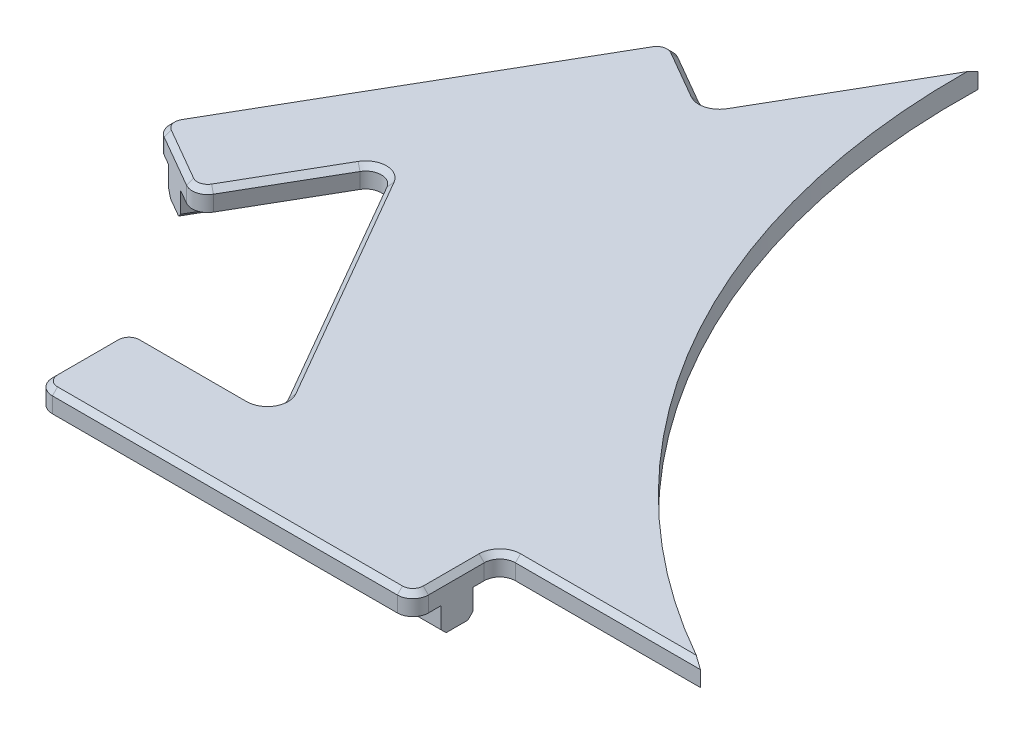
from build123d import *

# Parameters (mm, degrees)
BOSS_EXTRUDE1_DEPTH = 4
FILLET1_R           = 3
CUT_EXTRUDE1_DEPTH  = 5
FILLET4_R           = 3
CHAMFER1_SIZE       = 1
SKETCH3_R           = 140
CUT_EXTRUDE2_DEPTH  = 5
BOSS_EXTRUDE2_DEPTH = 5
CHAMFER2_SIZE       = 1


with BuildPart() as part:
    # Sketch1 → Boss-Extrude1 (new body)
    with BuildSketch(Plane(origin=(0, 0, 0), x_dir=(1, 0, 0), z_dir=(0, 1, 0))):
        Polygon((76, 10), (46.660254, 60.817931), (45.361216, 61.567931), (31.361216, 37.319219), (15.989265, 46.194219), (52.214265, 108.93776), (66.720191, 100.56276), (86.045101, 134.034486), (159.09982, 7.5), (120.45, 7.5), (120.45, -9.25), (48, -9.25), (48, 8.5), (76, 8.5), align=None)
    extrude(amount=BOSS_EXTRUDE1_DEPTH)

    # Fillet1
    fillet1_edges = [part.edges().sort_by_distance(p)[0] for p in [
        (48, 2, 9.25),
        (48, 2, -8.5),
        (31.361216, 2, -37.319219),
        (15.989265, 2, -46.194219),
        (52.214265, 2, -108.93776),
        (66.720191, 2, -100.56276),
        (120.45, 2, -7.5),
        (120.45, 2, 9.25),
    ]]
    fillet(fillet1_edges, radius=FILLET1_R)

    # Sketch2 → Cut-Extrude1 (cut, through all)
    with BuildSketch(Plane(origin=(0, 4, 0), x_dir=(1, 0, 0), z_dir=(0, 1, 0))):
        Polygon((46.660254, 60.817931), (45.794229, 62.317931), (45.361216, 61.567931), align=None)
        Polygon((76, 8.5), (76.866025, 8.5), (76, 10), align=None)
    extrude(amount=-CUT_EXTRUDE1_DEPTH, mode=Mode.SUBTRACT)

    # Fillet4
    fillet4_edges = [part.edges().sort_by_distance(p)[0] for p in [
        (45.794229, 2, -62.317931),
        (76.866025, 2, -8.5),
    ]]
    fillet(fillet4_edges, radius=FILLET4_R)

    # Chamfer1
    chamfer1_edges = [part.edges().sort_by_distance(p)[0] for p in [
        (61.330127, 4, -35.408965),
        (74.267949, 4, -10),
        (45.794229, 4, -59.317931),
        (23.67524, 4, -41.756719),
        (84.225, 4, 9.25),
        (120.45, 4, 0.875),
        (59.467228, 4, -104.75026),
        (34.101765, 4, -77.56599),
        (48, 4, 0.375),
        (119.57132, 4, 8.37132),
        (48.87868, 4, 8.37132),
        (48.87868, 4, -7.62132),
        (17.189564, 4, -46.515838),
        (52.535884, 4, -107.737461),
        (31.039597, 4, -38.519518),
        (66.398571, 4, -101.763059),
        (121.32868, 4, -6.62132),
    ]]
    chamfer(chamfer1_edges, length=CHAMFER1_SIZE)

    # Sketch3 → Cut-Extrude2 (cut, through all)
    with BuildSketch(Plane(origin=(0, 4, 0), x_dir=(1, 0, 0), z_dir=(0, 1, 0))):
        with Locations((226, 130.481161)):
            Circle(SKETCH3_R)
    extrude(amount=-CUT_EXTRUDE2_DEPTH, mode=Mode.SUBTRACT)

    # Sketch4 → Boss-Extrude2 (add)
    with BuildSketch(Plane.XZ):
        Polygon((20.665802, -43.494219), (56.890802, -106.23776), (62.26016, -103.13776), (26.03516, -40.394219), (23.350481, -41.944219), align=None)
        Polygon((48, 0.75), (48, 3.85), (120.45, 3.85), (120.45, -2.35), (48, -2.35), align=None)
    extrude(amount=BOSS_EXTRUDE2_DEPTH)

    # Chamfer2
    chamfer2_edges = [part.edges().sort_by_distance(p)[0] for p in [
        (84.225, -5, -2.35),
        (84.225, -5, 3.85),
        (38.778302, -5, -74.86599),
        (44.14766, -5, -71.76599),
    ]]
    chamfer(chamfer2_edges, length=CHAMFER2_SIZE)


solid = part.part
